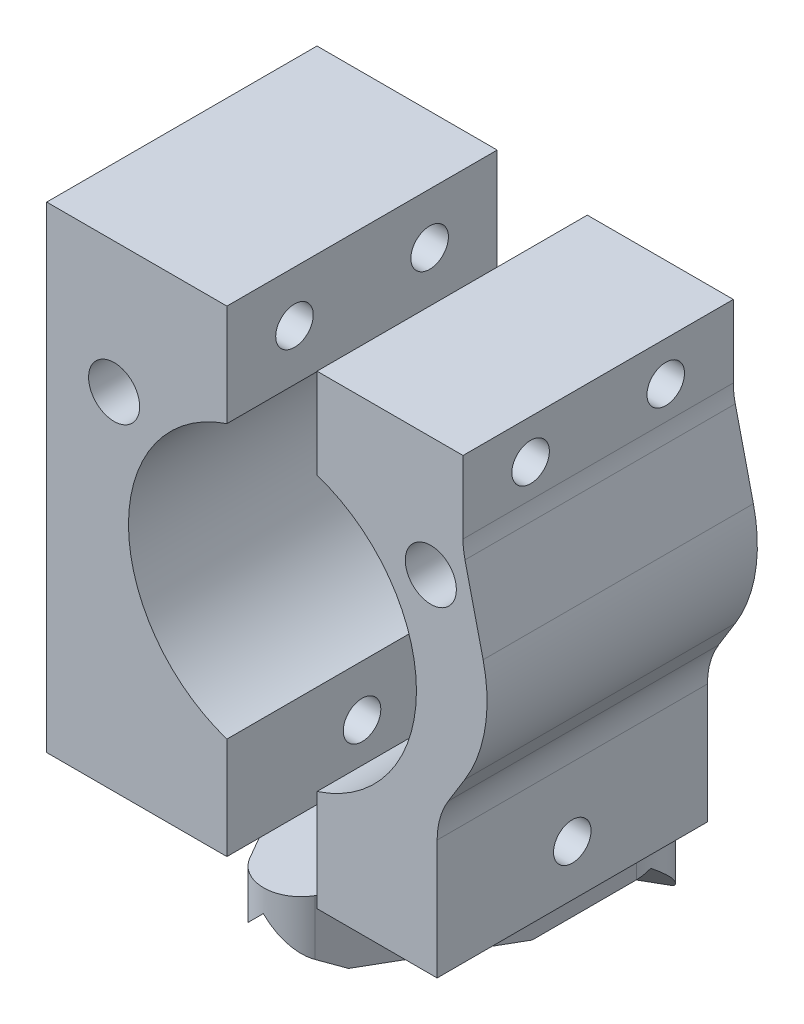
from build123d import *

# Parameters (mm, degrees)
SKETCH2_W                      = 12
SKETCH2_H                      = 18
EXTRUDE1_DEPTH                 = 31.75
EXTRUDE1_2_DEPTH               = 31.75
SKETCH4_R                      = 9.5885
MAGNET_CAVITY_DEPTH            = 44.163207712
SKETCH18_W                     = 1.25
SKETCH18_H                     = 30
M3X0_5_TAPPED_HOLE1_AT_2_COUNT = 2
M3X0_5_TAPPED_HOLE1_AT_2_PITCH = 9
M3X0_5_TAPPED_HOLE1_AT_3_COUNT = 2
M3X0_5_TAPPED_HOLE1_AT_3_PITCH = 25.395037131
M3_CLEARANCE_HOLE1_AT_2_COUNT  = 2
M3_CLEARANCE_HOLE1_AT_2_PITCH  = 21.091007592
EXTRUDE3_DEPTH                 = 44.163207712
EXTRUDE5_DEPTH                 = 4.5
EXTRUDE8_START                 = -8
EXTRUDE8_DEPTH                 = 36.406015976
CIRPATTERN1_COUNT              = 3


with BuildPart() as part:
    # Sketch2 → Extrude1 (new body)
    with BuildSketch(Plane(origin=(0, 4.5, 0), x_dir=(-1, 0, 0), z_dir=(0, 1, 0))):
        with Locations((9, 1.982307478)):
            Rectangle(SKETCH2_W, SKETCH2_H)
    extrude(amount=EXTRUDE1_DEPTH)


with BuildPart() as body_2:
    # Sketch2 → Extrude1 2 (new body)
    with BuildSketch(Plane(origin=(0, 4.5, 0), x_dir=(-1, 0, 0), z_dir=(0, 1, 0))):
        with Locations((-9, 1.982307478)):
            Rectangle(SKETCH2_W, SKETCH2_H)
    extrude(amount=EXTRUDE1_2_DEPTH)


with BuildPart() as magnet_cavity_tool:
    # Sketch4 → Magnet Cavity (new, through all)
    with BuildSketch(Plane.XY.offset(10.982307478)):
        with Locations((0.033766691, 20.375)):
            Circle(SKETCH4_R)
    extrude(amount=-MAGNET_CAVITY_DEPTH)


with BuildPart() as part_1:
    add(part.part)

    # Magnet Cavity: cut by magnet_cavity_tool
    add(magnet_cavity_tool.part, mode=Mode.SUBTRACT)


with BuildPart() as body_2_1:
    add(body_2.part)

    # Magnet Cavity: cut by magnet_cavity_tool
    add(magnet_cavity_tool.part, mode=Mode.SUBTRACT)


with BuildPart() as m3x0_5_tapped_hole1_tool:
    # Sketch18 → M3x0.5 Tapped Hole1 (revolve)
    with BuildSketch(Plane(origin=(15, 32.871578641, 6.482307478), x_dir=(0, 0, -1), z_dir=(0, 1, 0))):
        with Locations((0.625, 15)):
            Rectangle(SKETCH18_W, SKETCH18_H)
    m3x0_5_tapped_hole1 = revolve(axis=Axis((21.35, 32.871578641, 6.482307478), (-1, 0, 0)))


with BuildPart() as part_2:
    add(part_1.part)

    # M3x0.5 Tapped Hole1: cut by m3x0_5_tapped_hole1_tool
    add(m3x0_5_tapped_hole1_tool.part, mode=Mode.SUBTRACT)


with BuildPart() as body_2_2:
    add(body_2_1.part)

    # M3x0.5 Tapped Hole1: cut by m3x0_5_tapped_hole1_tool
    add(m3x0_5_tapped_hole1_tool.part, mode=Mode.SUBTRACT)


with BuildPart() as m3x0_5_tapped_hole1_at_2_tool:
    # M3x0.5 Tapped Hole1 at 2: M3x0.5 Tapped Hole1 ×2
    with Locations(*[(0, 0, -i * M3X0_5_TAPPED_HOLE1_AT_2_PITCH) for i in range(1, M3X0_5_TAPPED_HOLE1_AT_2_COUNT)]):
        add(m3x0_5_tapped_hole1)


with BuildPart() as part_3:
    add(part_2.part)

    # M3x0.5 Tapped Hole1 at 2: cut by m3x0_5_tapped_hole1_at_2_tool
    add(m3x0_5_tapped_hole1_at_2_tool.part, mode=Mode.SUBTRACT)


with BuildPart() as body_2_3:
    add(body_2_2.part)

    # M3x0.5 Tapped Hole1 at 2: cut by m3x0_5_tapped_hole1_at_2_tool
    add(m3x0_5_tapped_hole1_at_2_tool.part, mode=Mode.SUBTRACT)


with BuildPart() as m3x0_5_tapped_hole1_at_3_tool:
    # M3x0.5 Tapped Hole1 at 3: M3x0.5 Tapped Hole1 ×2
    with Locations(*[Vector(0, -0.984174866621225, -0.1771999771757721) * (i * M3X0_5_TAPPED_HOLE1_AT_3_PITCH) for i in range(1, M3X0_5_TAPPED_HOLE1_AT_3_COUNT)]):
        add(m3x0_5_tapped_hole1)


with BuildPart() as part_4:
    add(part_3.part)

    # M3x0.5 Tapped Hole1 at 3: cut by m3x0_5_tapped_hole1_at_3_tool
    add(m3x0_5_tapped_hole1_at_3_tool.part, mode=Mode.SUBTRACT)

    # Sketch24 → M3 Clearance Hole1 (revolve, cut)
    with BuildSketch(Plane(origin=(-10.511737105, 27.54122981, 10.982307478), x_dir=(0, -1, 0), z_dir=(1, 0, 0))):
        Polygon((0, 0), (0, 19.021463052), (1.7, 18), (1.7, 0), align=None)
    m3_clearance_hole1 = revolve(axis=Axis((-10.511737105, 27.54122981, 17.332307478), (0, 0, -1)), mode=Mode.SUBTRACT)



with BuildPart() as body_2_4:
    add(body_2_3.part)

    # M3x0.5 Tapped Hole1 at 3: cut by m3x0_5_tapped_hole1_at_3_tool
    add(m3x0_5_tapped_hole1_at_3_tool.part, mode=Mode.SUBTRACT)

    # M3 Clearance Hole1 at 2: M3 Clearance Hole1 ×2
    with Locations(*[(i * M3_CLEARANCE_HOLE1_AT_2_PITCH, 0, 0) for i in range(1, M3_CLEARANCE_HOLE1_AT_2_COUNT)]):
        add(m3_clearance_hole1, mode=Mode.SUBTRACT)

    # Trim Sketch → Extrude3 (cut, through all)
    with BuildSketch(Plane.XY.offset(10.982307478)):
        with BuildLine():
            Line((11, 12.456391912), (11, 4.5))
            Line((11, 4.5), (15, 4.5))
            Line((15, 4.5), (15, 36.25))
            Line((15, 36.25), (3, 36.25))
            Line((3, 36.25), (3, 35.497310661))
            Line((3, 35.497310661), (12.724200068, 35.497310661))
            Line((12.724200068, 35.497310661), (12.724200068, 30.679595884))
            ThreePointArc((12.724200068, 30.679595884), (12.757175017, 30.10630526), (12.855664924, 29.540576328))
            Line((12.855664924, 29.540576328), (14.062015368, 24.384247359))
            ThreePointArc((14.062015368, 24.384247359), (14.195982577, 20.505390111), (12.843027952, 16.867671794))
            Line((12.843027952, 16.867671794), (11.740958564, 15.075660139))
            ThreePointArc((11.740958564, 15.075660139), (11.188804349, 13.817419615), (11, 12.456391912))
        make_face()
    extrude(amount=-EXTRUDE3_DEPTH, mode=Mode.SUBTRACT)


with BuildPart() as part_5:
    add(part_4.part)

    add(body_2_4.part)  # Extrude5 merges body 2
    # Sketch1 → Extrude5 (add)
    with BuildSketch(Plane(origin=(0, 0, 0), x_dir=(1, 0, 0), z_dir=(0, 1, 0))):
        with BuildLine():
            Line((-9.989936491, 3.267692522), (-8.459547932, 0.616981784))
            Line((-8.459547932, 0.616981784), (-3.695452068, -7.634674306))
            Line((-3.695452068, -7.634674306), (-2.152576018, -10.307014014))
            ThreePointArc((-2.152576018, -10.307014014), (0.012487492, -11.557014014), (2.177551001, -10.307014014))
            Line((2.177551001, -10.307014014), (8.47827917, 0.606167299))
            Line((8.47827917, 0.606167299), (10.014911474, 3.267692522))
            ThreePointArc((10.014911474, 3.267692522), (10.014911474, 5.767692522), (7.849847964, 7.017692522))
            Line((7.849847964, 7.017692522), (4.764095865, 7.017692522))
            Line((4.764095865, 7.017692522), (-4.764095865, 7.017692522))
            Line((-4.764095865, 7.017692522), (-7.824872981, 7.017692522))
            ThreePointArc((-7.824872981, 7.017692522), (-9.989936491, 5.767692522), (-9.989936491, 3.267692522))
        make_face()
    extrude(amount=EXTRUDE5_DEPTH)

    # Sketch29 → Extrude8 (cut, through all)
    with BuildSketch(Plane(origin=(0, 0, -7.017692522), x_dir=(-1, 0, 0), z_dir=(0, 0, -1)).offset(EXTRUDE8_START)):
        Polygon((67.30851185, -64.30851185), (3, 0), (0, 3), (-3, 0), (-67.30851185, -64.30851185), (-67.30851185, -246.200451118), (67.30851185, -246.200451118), align=None)
    extrude8 = extrude(amount=-EXTRUDE8_DEPTH, mode=Mode.SUBTRACT)

    # CirPattern1: Extrude8 ×3 about axis
    cirpattern1_axis = Axis((0, 0, 1.982307478), (0, 1, 0))
    for i in range(1, CIRPATTERN1_COUNT):
        add(extrude8.rotate(cirpattern1_axis, i * 360 / CIRPATTERN1_COUNT), mode=Mode.SUBTRACT)


solid = part_5.part
